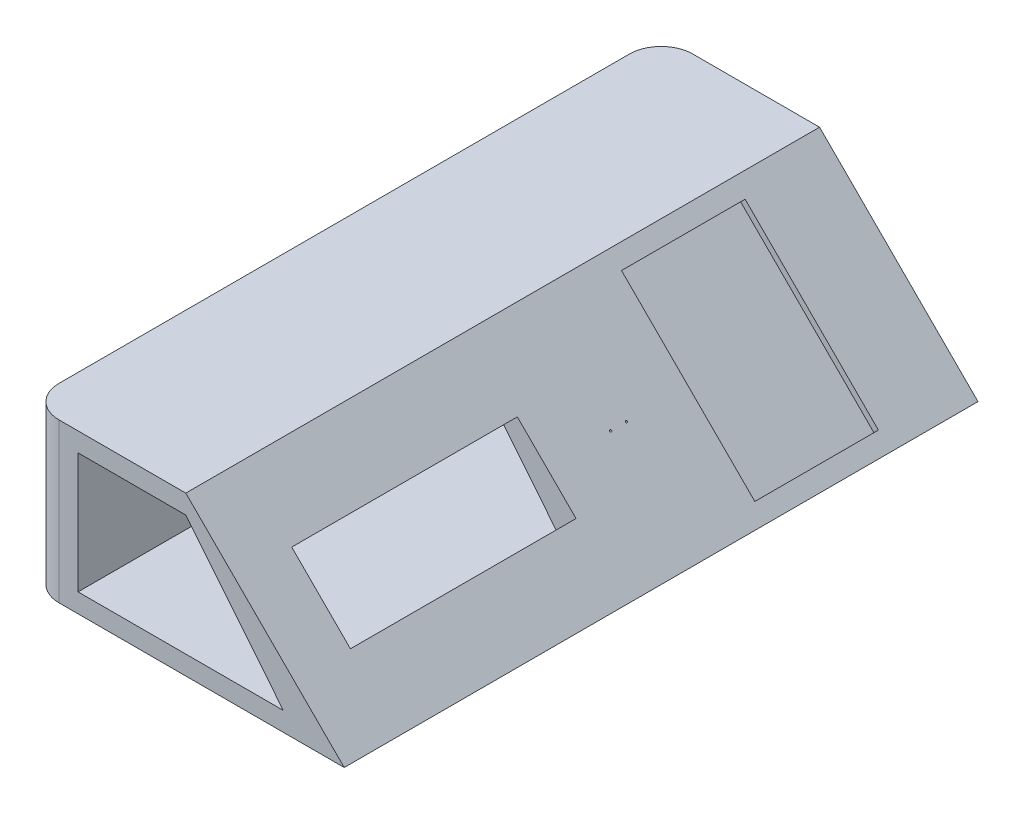
from build123d import *

# Parameters (mm, degrees)
BOSS_EXTRUDE1_DEPTH = 200
FILLET1_R           = 10
SKETCH2_W           = 39
SKETCH2_H           = 59.5
CUT_EXTRUDE1_DEPTH  = 2
SKETCH3_W           = 71.2
SKETCH3_H           = 26.2
CUT_EXTRUDE2_DEPTH  = 10
CUT_EXTRUDE4_DEPTH  = 215
SKETCH10_R          = 0.3
CUT_EXTRUDE5_DEPTH  = 10


with BuildPart() as part:
    # Sketch1 → Boss-Extrude1 (new body)
    with BuildSketch(Plane.XY):
        Polygon((0, 0), (100, 0), (50, 50), (0, 50), align=None)
    extrude(amount=BOSS_EXTRUDE1_DEPTH)

    # Fillet1
    fillet1_edges = [part.edges().sort_by_distance(p)[0] for p in [
        (0, 25, 200),
        (0, 25, 0),
    ]]
    fillet(fillet1_edges, radius=FILLET1_R)

    # Sketch2 → Cut-Extrude1 (cut)
    with BuildSketch(Plane(origin=(50, 50, 0), x_dir=(0, 0, -1), z_dir=(0.707106781, 0.707106781, 0))):
        with Locations((-46.962285567, -35.355339059)):
            Rectangle(SKETCH2_W, SKETCH2_H)
    extrude(amount=-CUT_EXTRUDE1_DEPTH, mode=Mode.SUBTRACT)

    # Sketch3 → Cut-Extrude2 (cut)
    with BuildSketch(Plane(origin=(50, 50, 0), x_dir=(0, 0, -1), z_dir=(0.707106781, 0.707106781, 0))):
        with Locations((-146.711084233, -35.355339059)):
            Rectangle(SKETCH3_W, SKETCH3_H)
    extrude(amount=-CUT_EXTRUDE2_DEPTH, mode=Mode.SUBTRACT)

    # Sketch6 → Cut-Extrude4 (cut)
    with BuildSketch(Plane.XY.offset(200)):
        Polygon((50, 44), (80.771793261, 6), (16, 6), (16, 44), align=None)
    extrude(amount=-CUT_EXTRUDE4_DEPTH, mode=Mode.SUBTRACT)

    # Sketch10 → Cut-Extrude5 (cut)
    with BuildSketch(Plane(origin=(50, 50, 0), x_dir=(0, 0, -1), z_dir=(0.707106781, 0.707106781, 0))):
        with Locations((-90.936655298, -35.355339059)):
            Circle(SKETCH10_R)
        with Locations((-85.936655298, -35.355339059)):
            Circle(SKETCH10_R)
    extrude(amount=-CUT_EXTRUDE5_DEPTH, mode=Mode.SUBTRACT)


solid = part.part
